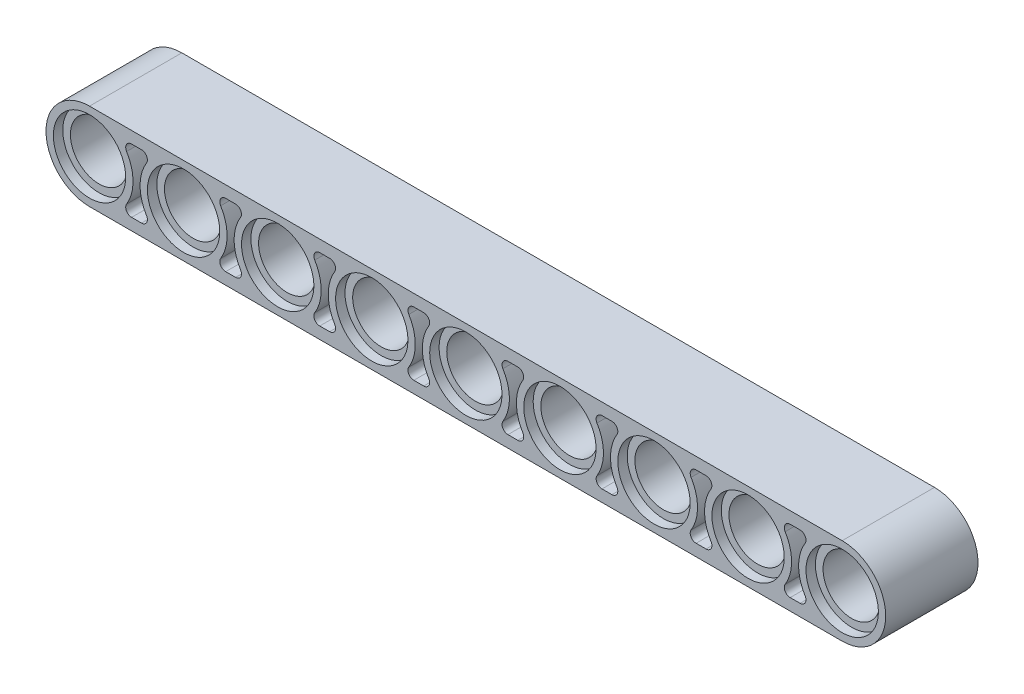
from build123d import *

# Parameters (mm, degrees)
BOSS_EXTRUDE1_DEPTH = 7.85
BOSS_EXTRUDE2_DEPTH = 0.6
LPATTERN1_COUNT     = 9
LPATTERN1_PITCH     = 8
CUT_EXTRUDE1_DEPTH  = 8.85


with BuildPart() as part:
    # Sketch1 → Revolve1 (revolve)
    with BuildSketch(Plane(origin=(0, 0, 0), x_dir=(1, 0, 0), z_dir=(0, 1, 0))):
        Polygon((-3.7, 3.925), (-3.7, -3.925), (-3.075, -3.925), (-3.075, -3.125), (-2.425, -3.125), (-2.425, 3.125), (-3.075, 3.125), (-3.075, 3.925), align=None)
    revolve1 = revolve(axis=Axis((0, 0, -2.425), (0, 0, 1)))

    # Sketch2 → Boss-Extrude1 (add)
    with BuildSketch(Plane.XY.offset(3.925)):
        with BuildLine():
            Line((0, 3.7), (-8, 3.7))
            Line((-8, 3.7), (-8, 3.2))
            ThreePointArc((-8, 3.2), (-4.8, 0), (-8, -3.2))
            Line((-8, -3.2), (-8, -3.7))
            Line((-8, -3.7), (0, -3.7))
            Line((0, -3.7), (0, -3.2))
            ThreePointArc((0, -3.2), (-3.2, 0), (0, 3.2))
            Line((0, 3.2), (0, 3.7))
        make_face()
        with BuildLine():
            Line((-3.577708764, -2.7), (-4.422291236, -2.7))
            ThreePointArc((-4.422291236, -2.7), (-4.858727016, -2.443975018), (-4.848208946, -1.938095238))
            ThreePointArc((-4.848208946, -1.938095238), (-4.3, 0), (-4.848208946, 1.938095238))
            ThreePointArc((-4.848208946, 1.938095238), (-4.858727016, 2.443975018), (-4.422291236, 2.7))
            Line((-4.422291236, 2.7), (-3.577708764, 2.7))
            ThreePointArc((-3.577708764, 2.7), (-3.141272984, 2.443975018), (-3.151791054, 1.938095238))
            ThreePointArc((-3.151791054, 1.938095238), (-3.7, 0), (-3.151791054, -1.938095238))
            ThreePointArc((-3.151791054, -1.938095238), (-3.141272984, -2.443975018), (-3.577708764, -2.7))
        make_face(mode=Mode.SUBTRACT)
    boss_extrude1 = extrude(amount=-BOSS_EXTRUDE1_DEPTH)

    # Sketch3 → Boss-Extrude2 (add, symmetric)
    with BuildSketch(Plane.XY):
        with BuildLine():
            Line((-3.577708764, 2.7), (-4.422291236, 2.7))
            ThreePointArc((-4.422291236, 2.7), (-4.858727016, 2.443975018), (-4.848208946, 1.938095238))
            ThreePointArc((-4.848208946, 1.938095238), (-4.3, 0), (-4.848208946, -1.938095238))
            ThreePointArc((-4.848208946, -1.938095238), (-4.858727016, -2.443975018), (-4.422291236, -2.7))
            Line((-4.422291236, -2.7), (-3.577708764, -2.7))
            ThreePointArc((-3.577708764, -2.7), (-3.141272984, -2.443975018), (-3.151791054, -1.938095238))
            ThreePointArc((-3.151791054, -1.938095238), (-3.7, 0), (-3.151791054, 1.938095238))
            ThreePointArc((-3.151791054, 1.938095238), (-3.141272984, 2.443975018), (-3.577708764, 2.7))
        make_face()
    boss_extrude2 = extrude(amount=BOSS_EXTRUDE2_DEPTH, both=True)

    # LPattern1: Revolve1, Boss-Extrude1, Boss-Extrude2 ×9
    with Locations(*[(i * LPATTERN1_PITCH, 0, 0) for i in range(1, LPATTERN1_COUNT)]):
        add(revolve1)
        add(boss_extrude1)
        add(boss_extrude2)

    # Sketch4 → Cut-Extrude1 (cut, through all)
    with BuildSketch(Plane.XY.offset(3.925)):
        with BuildLine():
            Line((0, 3.7), (-8, 3.7))
            Line((-8, 3.7), (-8, -3.7))
            Line((-8, -3.7), (0, -3.7))
            ThreePointArc((0, -3.7), (-3.7, 0), (0, 3.7))
        make_face()
    extrude(amount=-CUT_EXTRUDE1_DEPTH, mode=Mode.SUBTRACT)


solid = part.part
